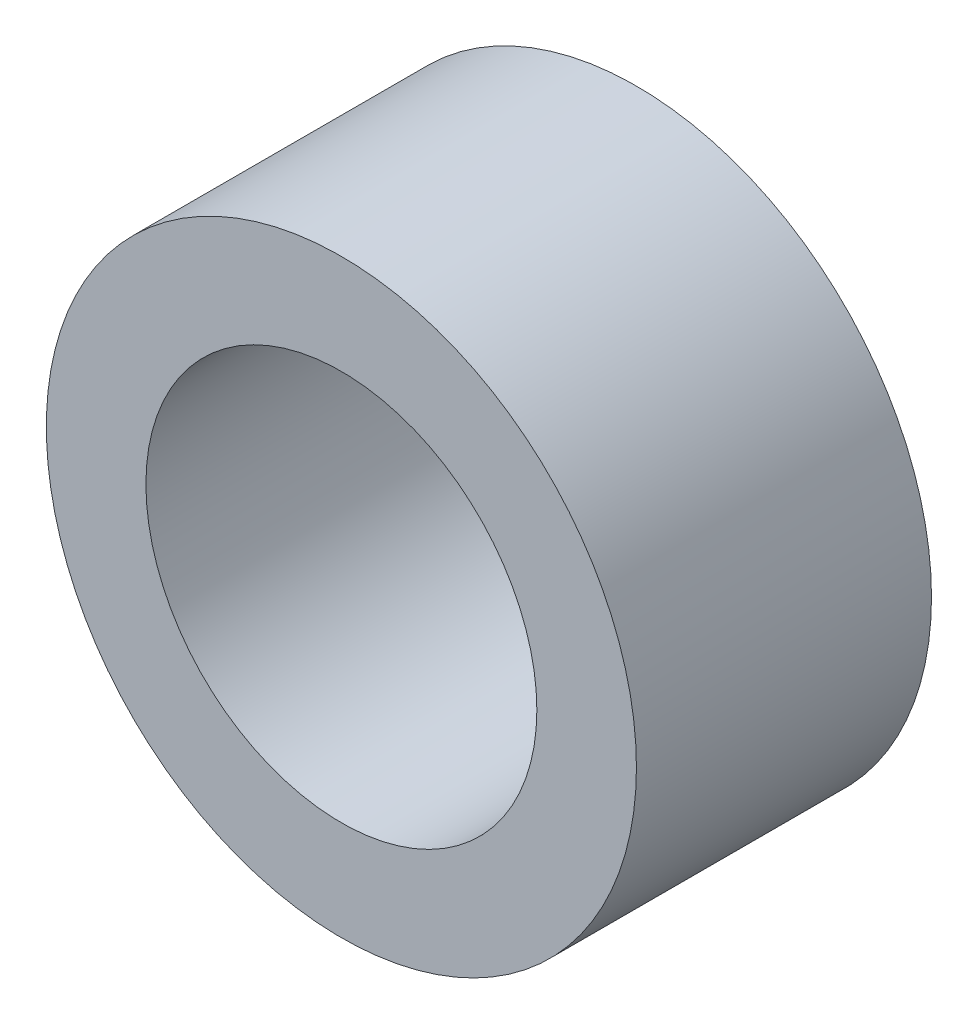
from build123d import *

# Parameters (mm, degrees)
SKETCH1_R           = 4
SKETCH1_R_2         = 2.65
EXTRUDE1_DEPTH      = 2
EXTRUDE1_DEPTH_BACK = 2


with BuildPart() as part:
    # Sketch1 → Extrude1 (new body, two sides)
    with BuildSketch(Plane.XY) as extrude1_sk:
        Circle(SKETCH1_R)
        Circle(SKETCH1_R_2, mode=Mode.SUBTRACT)
    extrude(amount=EXTRUDE1_DEPTH)
    extrude(extrude1_sk.sketch, amount=-EXTRUDE1_DEPTH_BACK)


solid = part.part
